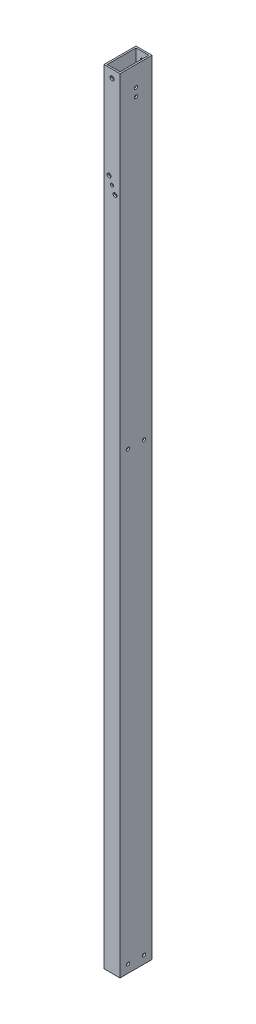
from build123d import *

# Parameters (mm, degrees)
SKETCH1_W           = 25.4
SKETCH1_H           = 50.8
SKETCH1_W_2         = 20.32
SKETCH1_H_2         = 45.72
EXTRUDE_THIN1_DEPTH = 1244.6
SKETCH2_R           = 2.4892
CUT_EXTRUDE1_DEPTH  = 26.4
SKETCH3_R           = 2.5019
SKETCH3_R_2         = 2.4892
CUT_EXTRUDE2_DEPTH  = 26.4
SKETCH5_R           = 2.4892
CUT_EXTRUDE3_DEPTH  = 51.8
SKETCH6_R           = 3.175
CUT_EXTRUDE4_DEPTH  = 51.8
SKETCH7_R           = 3.175
CUT_EXTRUDE5_DEPTH  = 51.8


with BuildPart() as part:
    # Sketch1 → Extrude-Thin1 (new body)
    with BuildSketch(Plane(origin=(0, 0, 0), x_dir=(1, 0, 0), z_dir=(0, 1, 0))):
        with Locations((12.7, 25.4)):
            Rectangle(SKETCH1_W, SKETCH1_H)
        with Locations((12.7, 25.4)):
            Rectangle(SKETCH1_W_2, SKETCH1_H_2, mode=Mode.SUBTRACT)
    extrude(amount=EXTRUDE_THIN1_DEPTH)

    # Sketch2 → Cut-Extrude1 (cut, through all)
    with BuildSketch(Plane(origin=(25.4, 0, 0), x_dir=(0, 0, -1), z_dir=(1, 0, 0))):
        with Locations((25.4, 1200.15)):
            Circle(SKETCH2_R)
        with Locations((25.4, 1212.85)):
            Circle(SKETCH2_R)
    extrude(amount=-CUT_EXTRUDE1_DEPTH, mode=Mode.SUBTRACT)

    # Sketch3 → Cut-Extrude2 (cut, through all)
    with BuildSketch(Plane.ZY):
        with Locations((-12.7, 721.632068306)):
            Circle(SKETCH3_R)
        with Locations((-38.1, 721.632068306)):
            Circle(SKETCH3_R)
        with Locations((-12.7, 12.960193373)):
            Circle(SKETCH3_R_2)
        with Locations((-38.1, 12.7)):
            Circle(SKETCH3_R_2)
    extrude(amount=-CUT_EXTRUDE2_DEPTH, mode=Mode.SUBTRACT)

    # Sketch5 → Cut-Extrude3 (cut, through all)
    with BuildSketch(Plane(origin=(0, 0, -50.8), x_dir=(-1, 0, 0), z_dir=(0, 0, -1))):
        with Locations((-12.7, 1084.8045868)):
            Circle(SKETCH5_R)
    extrude(amount=-CUT_EXTRUDE3_DEPTH, mode=Mode.SUBTRACT)

    # Sketch6 → Cut-Extrude4 (cut, through all)
    with BuildSketch(Plane(origin=(0, 0, -50.8), x_dir=(-1, 0, 0), z_dir=(0, 0, -1))):
        with Locations((-12.7, 1231.9)):
            Circle(SKETCH6_R)
    extrude(amount=-CUT_EXTRUDE4_DEPTH, mode=Mode.SUBTRACT)

    # Sketch7 → Cut-Extrude5 (cut, through all)
    with BuildSketch(Plane.XY):
        with Locations((7.9375, 1095.9170868)):
            Circle(SKETCH7_R)
        with Locations((17.4625, 1073.6920868)):
            Circle(SKETCH7_R)
    extrude(amount=-CUT_EXTRUDE5_DEPTH, mode=Mode.SUBTRACT)


solid = part.part
